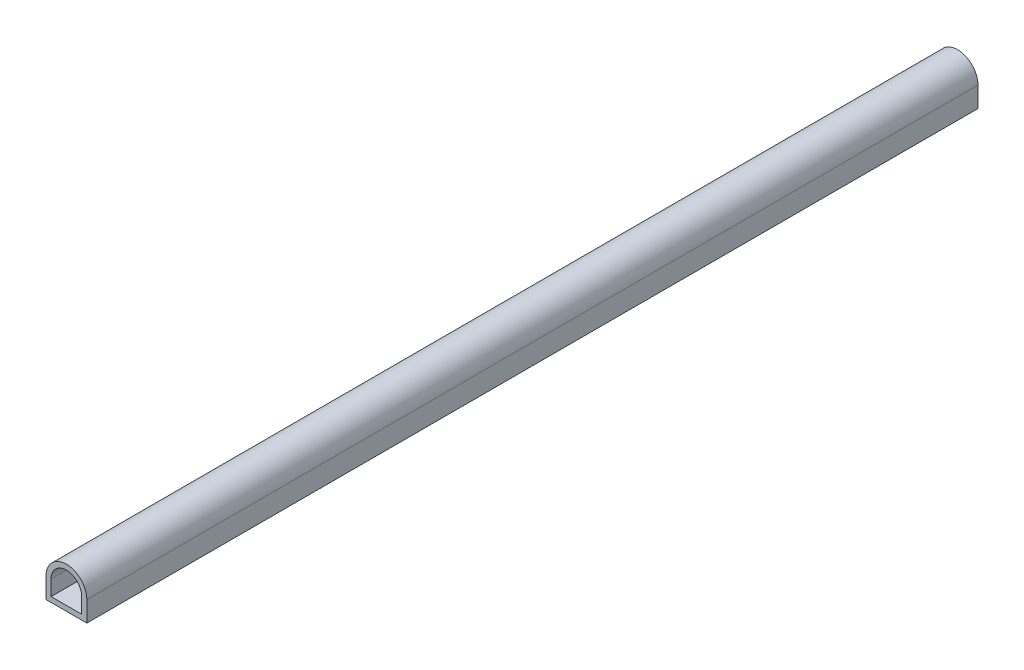
from build123d import *

# Parameters (mm, degrees)
EXTRUSION1_DEPTH = 131


with BuildPart() as part:
    # Esquisse1 → Extrusion1 (new body)
    with BuildSketch(Plane.XY):
        with BuildLine():
            Line((-3, -3), (3, -3))
            Line((3, -3), (3, 0))
            ThreePointArc((3, 0), (0, 3), (-3, 0))
            Line((-3, 0), (-3, -3))
        make_face()
        with BuildLine():
            Line((-2.25, -2.25), (2.25, -2.25))
            Line((2.25, -2.25), (2.25, 0))
            ThreePointArc((2.25, 0), (0, 2.25), (-2.25, 0))
            Line((-2.25, 0), (-2.25, -2.25))
        make_face(mode=Mode.SUBTRACT)
    extrude(amount=EXTRUSION1_DEPTH)


solid = part.part
